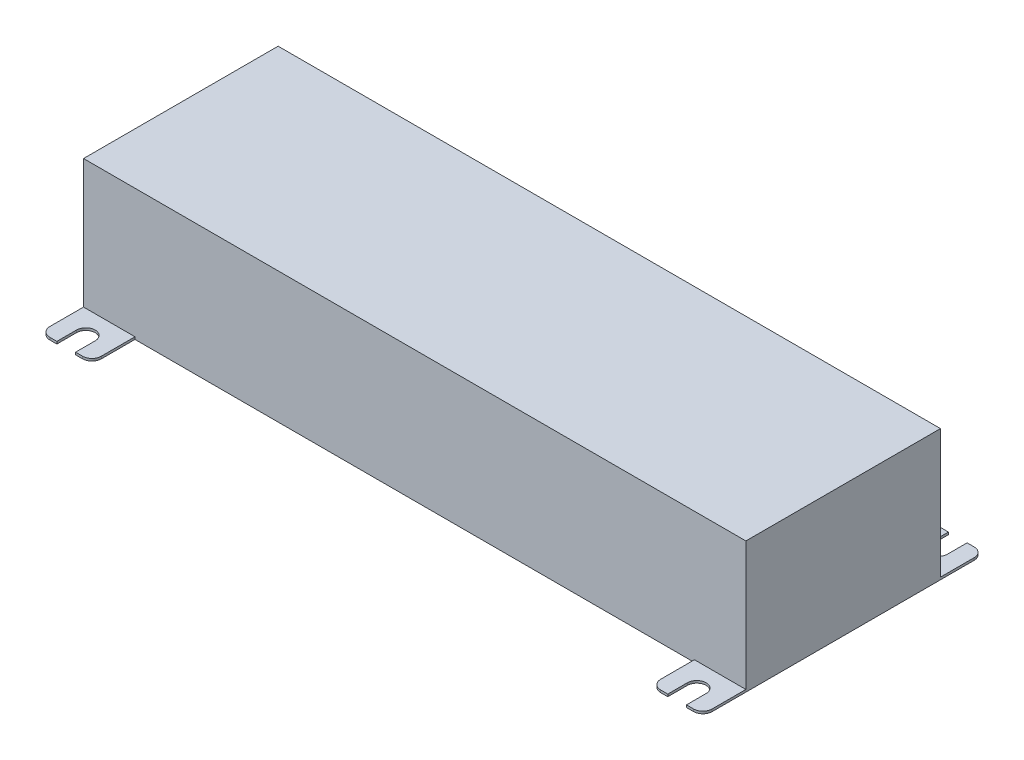
from build123d import *

# Parameters (mm, degrees)
SCHIZZO1_W                   = 141.6
SCHIZZO1_H                   = 41.6
ESTRUSIONE_ESTRUSIONE1_DEPTH = 28
ESTRUSIONE_ESTRUSIONE2_DEPTH = 0.5


with BuildPart() as part:
    # Schizzo1 → Estrusione-Estrusione1 (new body)
    with BuildSketch(Plane(origin=(0, 0, 0), x_dir=(1, 0, 0), z_dir=(0, 1, 0))):
        Rectangle(SCHIZZO1_W, SCHIZZO1_H)
    extrude(amount=ESTRUSIONE_ESTRUSIONE1_DEPTH)

    # Schizzo2 → Estrusione-Estrusione2 (add)
    with BuildSketch(Plane(origin=(0, 0, 0), x_dir=(1, 0, 0), z_dir=(0, 1, 0))):
        with BuildLine():
            Line((-70.8, 20.8), (-70.8, 28))
            ThreePointArc((-70.8, 28), (-70.214213562, 29.414213562), (-68.8, 30))
            Line((-68.8, 30), (-67.3, 30))
            Line((-67.3, 30), (-67.3, 25.8))
            ThreePointArc((-67.3, 25.8), (-65.3, 23.8), (-63.3, 25.8))
            Line((-63.3, 25.8), (-63.3, 30))
            Line((-63.3, 30), (-61.8, 30))
            ThreePointArc((-61.8, 30), (-60.385786438, 29.414213562), (-59.8, 28))
            Line((-59.8, 28), (-59.8, 20.8))
            Line((-59.8, 20.8), (-70.8, 20.8))
        make_face()
        with BuildLine():
            Line((-63.3, -30), (-61.8, -30))
            ThreePointArc((-61.8, -30), (-60.385786438, -29.414213562), (-59.8, -28))
            Line((-59.8, -28), (-59.8, -20.8))
            Line((-59.8, -20.8), (-70.8, -20.8))
            Line((-70.8, -20.8), (-70.8, -28))
            ThreePointArc((-70.8, -28), (-70.214213562, -29.414213562), (-68.8, -30))
            Line((-68.8, -30), (-67.3, -30))
            Line((-67.3, -30), (-67.3, -25.8))
            ThreePointArc((-67.3, -25.8), (-65.3, -23.8), (-63.3, -25.8))
            Line((-63.3, -25.8), (-63.3, -30))
        make_face()
        with BuildLine():
            Line((63.3, -30), (61.8, -30))
            ThreePointArc((61.8, -30), (60.385786438, -29.414213562), (59.8, -28))
            Line((59.8, -28), (59.8, -20.8))
            Line((59.8, -20.8), (70.8, -20.8))
            Line((70.8, -20.8), (70.8, -28))
            ThreePointArc((70.8, -28), (70.214213562, -29.414213562), (68.8, -30))
            Line((68.8, -30), (67.3, -30))
            Line((67.3, -30), (67.3, -25.8))
            ThreePointArc((67.3, -25.8), (65.3, -23.8), (63.3, -25.8))
            Line((63.3, -25.8), (63.3, -30))
        make_face()
        with BuildLine():
            Line((63.3, 30), (61.8, 30))
            ThreePointArc((61.8, 30), (60.385786438, 29.414213562), (59.8, 28))
            Line((59.8, 28), (59.8, 20.8))
            Line((59.8, 20.8), (70.8, 20.8))
            Line((70.8, 20.8), (70.8, 28))
            ThreePointArc((70.8, 28), (70.214213562, 29.414213562), (68.8, 30))
            Line((68.8, 30), (67.3, 30))
            Line((67.3, 30), (67.3, 25.8))
            ThreePointArc((67.3, 25.8), (65.3, 23.8), (63.3, 25.8))
            Line((63.3, 25.8), (63.3, 30))
        make_face()
    extrude(amount=ESTRUSIONE_ESTRUSIONE2_DEPTH)


solid = part.part
